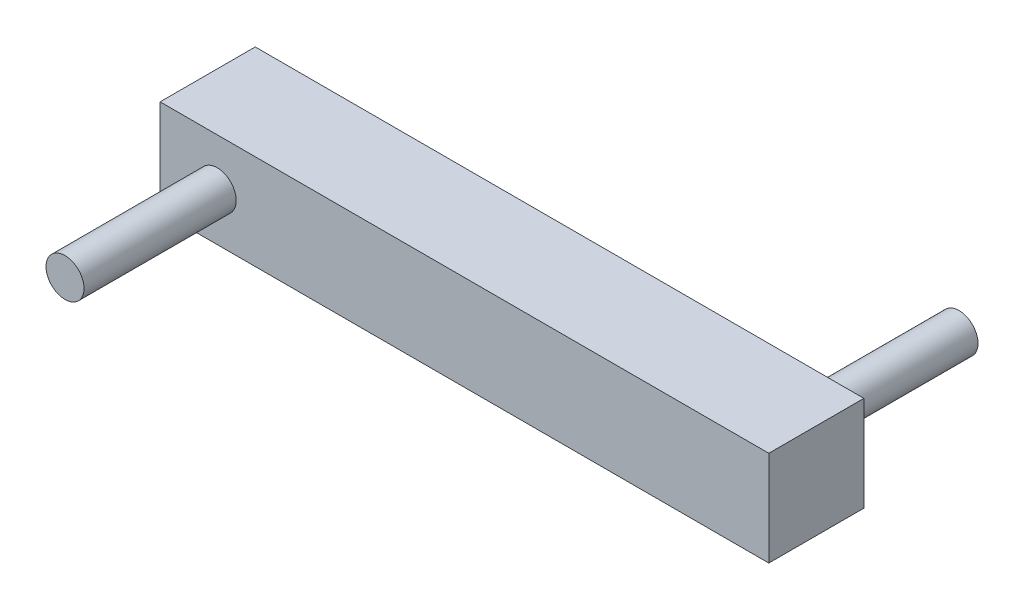
from build123d import *

# Parameters (mm, degrees)
SKETCH1_W           = 16
SKETCH1_H           = 2.5
BOSS_EXTRUDE1_DEPTH = 1.25
SKETCH2_R           = 0.5
BOSS_EXTRUDE2_DEPTH = 4
SKETCH3_R           = 0.5
BOSS_EXTRUDE3_DEPTH = 4


with BuildPart() as part:
    # Sketch1 → Boss-Extrude1 (new body, symmetric)
    with BuildSketch(Plane.XY):
        with Locations((8, 1.25)):
            Rectangle(SKETCH1_W, SKETCH1_H)
    extrude(amount=BOSS_EXTRUDE1_DEPTH, both=True)

    # Sketch2 → Boss-Extrude2 (add)
    with BuildSketch(Plane.XY.offset(1.25)):
        with Locations((1.5, 1.25)):
            Circle(SKETCH2_R)
    extrude(amount=BOSS_EXTRUDE2_DEPTH)

    # Sketch3 → Boss-Extrude3 (add)
    with BuildSketch(Plane(origin=(0, 0, -1.25), x_dir=(-1, 0, 0), z_dir=(0, 0, -1))):
        with Locations((-14.5, 1.25)):
            Circle(SKETCH3_R)
    extrude(amount=BOSS_EXTRUDE3_DEPTH)


solid = part.part
